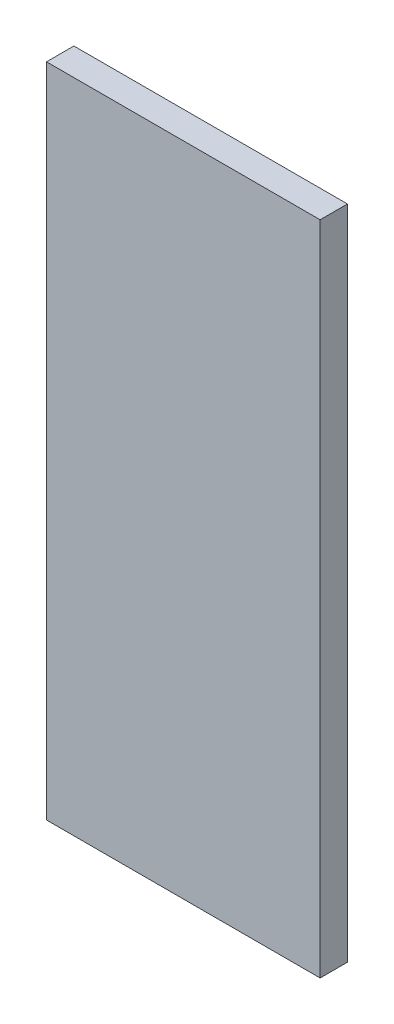
from build123d import *

# Parameters (mm, degrees)
SKETCH1_W           = 63.5
SKETCH1_H           = 152.4
BOSS_EXTRUDE1_DEPTH = 6.35


with BuildPart() as part:
    # Sketch1 → Boss-Extrude1 (new body)
    with BuildSketch(Plane.XY):
        with Locations((-1366.210453354, 35.459021407)):
            Rectangle(SKETCH1_W, SKETCH1_H)
    extrude(amount=BOSS_EXTRUDE1_DEPTH)


solid = part.part
